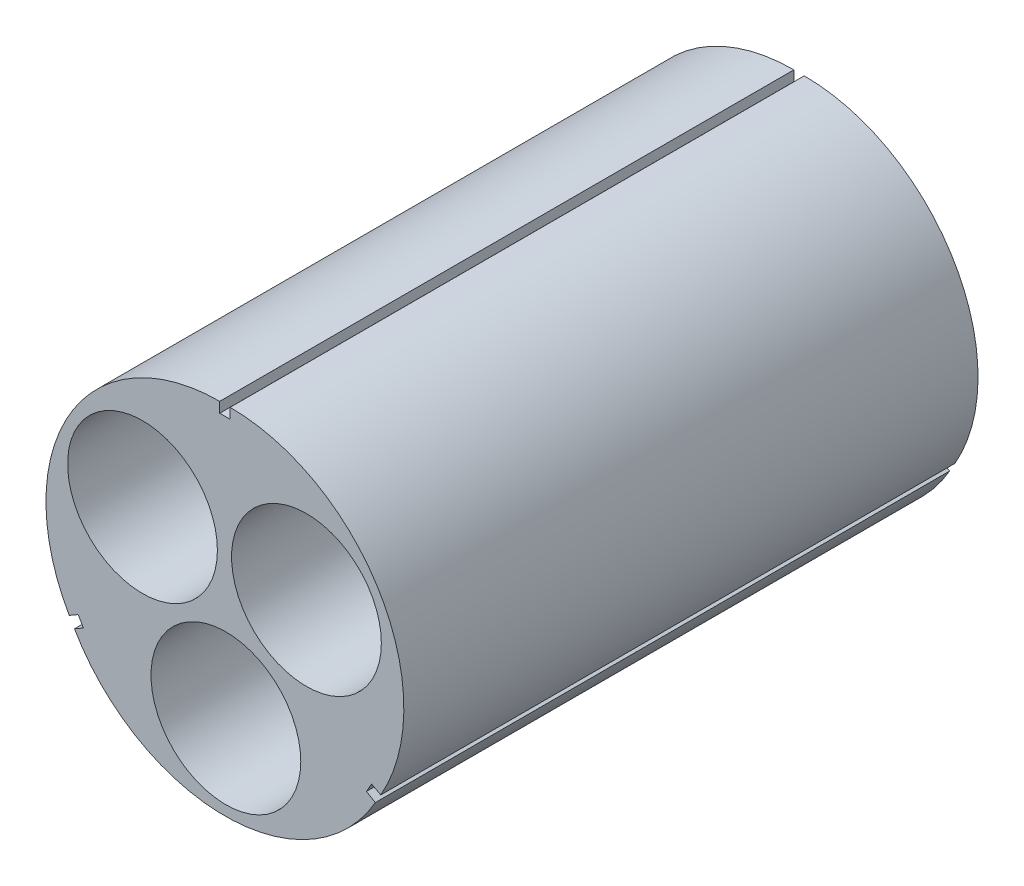
from build123d import *

# Parameters (mm, degrees)
SKETCH1_R           = 9.144
BOSS_EXTRUDE1_DEPTH = 70.104


with BuildPart() as part:
    # Sketch1 → Boss-Extrude1 (new body)
    with BuildSketch(Plane.XY):
        with BuildLine():
            Line((0, 20.32), (-0.635, 20.32))
            Line((-0.635, 20.32), (-0.635, 21.580659744))
            ThreePointArc((-0.635, 21.580659744), (-19.006899569, 10.973638583), (-19.006899569, -10.240403741))
            Line((-19.006899569, -10.240403741), (-17.915136205, -9.610073869))
            Line((-17.915136205, -9.610073869), (-17.597636205, -10.16))
            Line((-17.597636205, -10.16), (-17.280136205, -10.709926131))
            Line((-17.280136205, -10.709926131), (-18.371899569, -11.340256004))
            ThreePointArc((-18.371899569, -11.340256004), (0, -21.947277165), (18.371899569, -11.340256004))
            Line((18.371899569, -11.340256004), (17.280136205, -10.709926131))
            Line((17.280136205, -10.709926131), (17.597636205, -10.16))
            Line((17.597636205, -10.16), (17.915136205, -9.610073869))
            Line((17.915136205, -9.610073869), (19.025544668, -10.205721439))
            ThreePointArc((19.025544668, -10.205721439), (18.996550601, 10.990773387), (0.635, 21.580659744))
            Line((0.635, 21.580659744), (0.635, 20.32))
            Line((0.635, 20.32), (0, 20.32))
        make_face()
        with Locations((0.118855304, -11.557)):
            Circle(SKETCH1_R, mode=Mode.SUBTRACT)
        with Locations((9.955579479, 5.869470694)):
            Circle(SKETCH1_R, mode=Mode.SUBTRACT)
        with Locations((-10.060900468, 5.687049391)):
            Circle(SKETCH1_R, mode=Mode.SUBTRACT)
    extrude(amount=BOSS_EXTRUDE1_DEPTH)


solid = part.part
